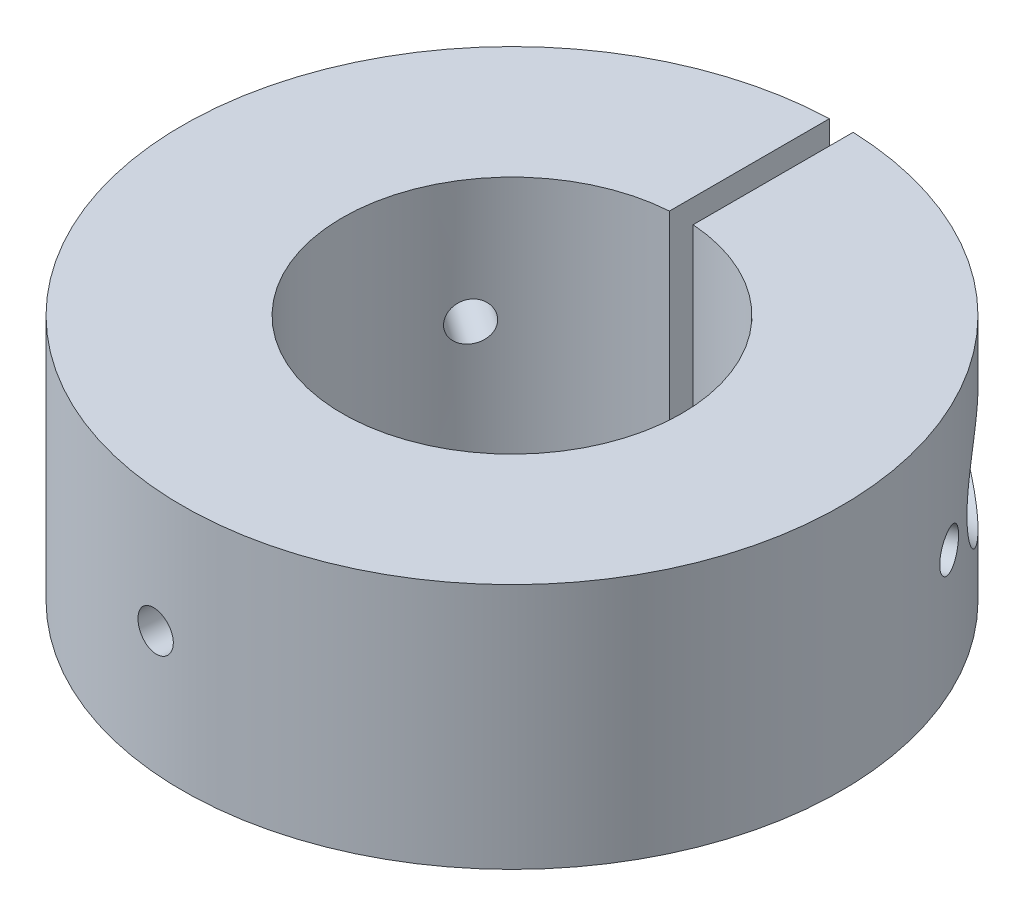
from build123d import *

# Parameters (mm, degrees)
BOSS_EXTRUDE1_DEPTH        = 7.9375
M3X0_5_TAPPED_HOLE1_REACH  = 50.846
M3X0_5_TAPPED_HOLE1_BORE_R = 1.25
CIRPATTERN1_COUNT          = 3


with BuildPart() as part:
    # Sketch1 → Boss-Extrude1 (new, symmetric)
    with BuildSketch(Plane(origin=(0, 0, 0), x_dir=(1, 0, 0), z_dir=(0, 1, 0))):
        with BuildLine():
            Line((-0.762, 21.195306957), (-0.762, 10.895386179))
            ThreePointArc((-0.762, 10.895386179), (0, -10.922), (0.762, 10.895386179))
            Line((0.762, 10.895386179), (0.762, 21.195306957))
            ThreePointArc((0.762, 21.195306957), (0, -21.209), (-0.762, 21.195306957))
        make_face()
    extrude(amount=BOSS_EXTRUDE1_DEPTH, both=True)

    # Sketch2 → Cut-Revolve1 (revolve, cut)
    with BuildSketch(Plane(origin=(0, 0, 0), x_dir=(1, 0, 0), z_dir=(0, 1, 0)), mode=Mode.PRIVATE) as cut_revolve1_sk:
        Polygon((-16.24122954, 13.6398), (0.762, 13.6398), (0.762, 13.1191), (4.142955705, 13.1191), (4.142955705, 11.39825), (17.885792628, 11.39825), (17.885792628, 15.367), (-16.24122954, 15.367), align=None)
    revolve(cut_revolve1_sk.sketch.rotate(Axis((-16.24122954, 0, -15.367), (-1, 0, 0)), 180), axis=Axis((-16.24122954, 0, -15.367), (-1, 0, 0)), mode=Mode.SUBTRACT)

    # M3x0.5 Tapped Hole1 bore (on position points) → M3x0.5 Tapped Hole1 (cut, up to next)
    with BuildSketch(Plane(origin=(-1.848486148, 0, 21.128293352), x_dir=(0.996194698092, 0, 0.087155742748), z_dir=(-0.087155742748, 0, 0.996194698092)), mode=Mode.PRIVATE) as m3x0_5_tapped_hole1_sk1:
        Circle(M3X0_5_TAPPED_HOLE1_BORE_R)
    m3x0_5_tapped_hole1_tool1 = extrude(m3x0_5_tapped_hole1_sk1.sketch, amount=-M3X0_5_TAPPED_HOLE1_REACH, mode=Mode.PRIVATE) & part.part
    m3x0_5_tapped_hole1 = m3x0_5_tapped_hole1_tool1.solids().sort_by_distance((-1.848486, 0, 21.128293))[0]
    add(m3x0_5_tapped_hole1, mode=Mode.SUBTRACT)

    # CirPattern1: M3x0.5 Tapped Hole1 ×3 about axis
    cirpattern1_axis = Axis((0, 7.9375, 0), (0, -1, 0))
    for i in range(1, CIRPATTERN1_COUNT):
        add(m3x0_5_tapped_hole1.rotate(cirpattern1_axis, i * 360 / CIRPATTERN1_COUNT), mode=Mode.SUBTRACT)


solid = part.part
